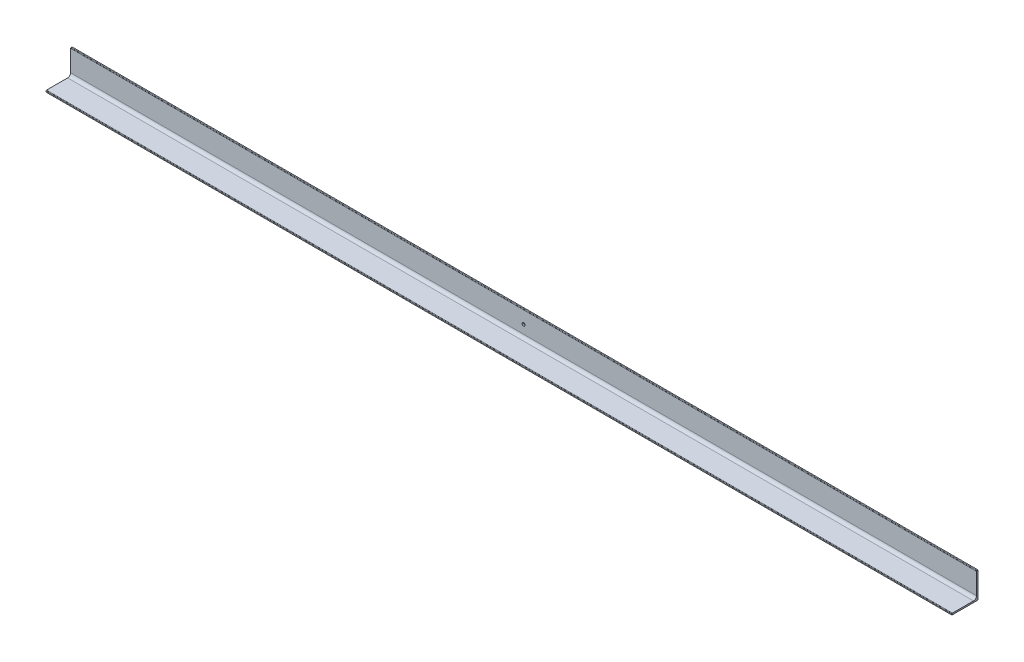
from build123d import *

# Parameters (mm, degrees)
BASE_DEPTH          = 1215
SKETCH_1_R          = 4
CUT_EXTRUDE_1_DEPTH = 5


with BuildPart() as part:
    # Sketch1 → Base (new body, symmetric)
    with BuildSketch(Plane.YZ):
        with BuildLine():
            Line((0, 70), (0, 0))
            Line((0, 0), (70, 0))
            Line((70, 0), (70, 2.666666667))
            ThreePointArc((70, 2.666666667), (69.609475708, 3.609475708), (68.666666667, 4))
            Line((68.666666667, 4), (12, 4))
            ThreePointArc((12, 4), (6.343145751, 6.343145751), (4, 12))
            Line((4, 12), (4, 68.666666667))
            ThreePointArc((4, 68.666666667), (3.609475708, 69.609475708), (2.666666667, 70))
            Line((2.666666667, 70), (0, 70))
        make_face()
    extrude(amount=BASE_DEPTH, both=True)

    # 草图1 → 切除-拉伸1 (cut, through all)
    with BuildSketch(Plane.XY.offset(4)):
        with Locations((0, 35)):
            Circle(SKETCH_1_R)
    extrude(amount=-CUT_EXTRUDE_1_DEPTH, mode=Mode.SUBTRACT)


solid = part.part
